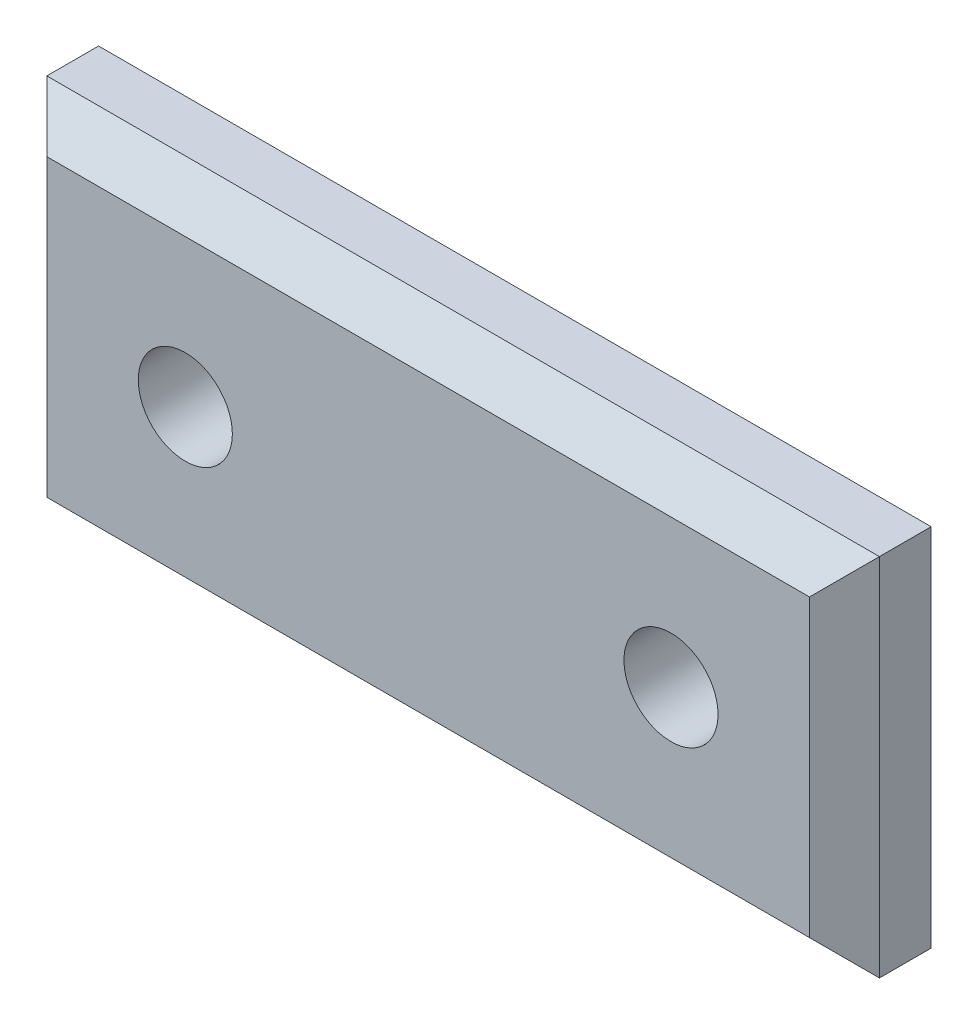
from build123d import *

# Parameters (mm, degrees)
SKETCH2_W             = 38.1
SKETCH2_H             = 16.7005
BOSS_EXTRUDE1_DEPTH   = 3.96875
F_8_CLEARANCE_HOLE1_D = 4.3053
CHAMFER1_SIZE         = 1.6002


with BuildPart() as part:
    # Sketch2 → Boss-Extrude1 (new body)
    with BuildSketch(Plane.XY):
        Rectangle(SKETCH2_W, SKETCH2_H)
    extrude(amount=BOSS_EXTRUDE1_DEPTH)

    # #8 Clearance Hole1 (through all)
    with Locations(Plane.XY.offset(3.96875)):
        with Locations((-11.1125, 0), (11.1125, 0)):
            Hole(F_8_CLEARANCE_HOLE1_D / 2)

    # Chamfer1
    chamfer1_edges = [part.edges().sort_by_distance(p)[0] for p in [
        (-19.05, 0, 3.96875),
        (0, -8.35025, 3.96875),
        (19.05, 0, 3.96875),
        (0, 8.35025, 3.96875),
    ]]
    chamfer(chamfer1_edges, length=CHAMFER1_SIZE)


solid = part.part
